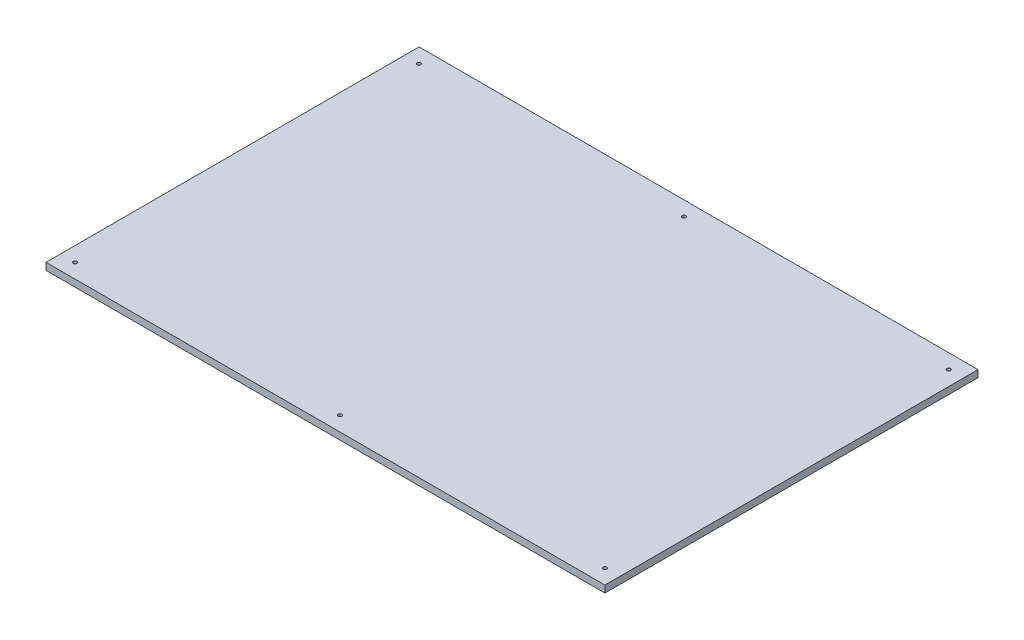
from build123d import *

# Parameters (mm, degrees)
SKETCH1_W                       = 2030
SKETCH1_H                       = 1355
BOSS_EXTRUDE1_DEPTH             = 25.4
CBORE_FOR_M12_SHCS1_D           = 13.5
CBORE_FOR_M12_SHCS1_CBORE_D     = 20
CBORE_FOR_M12_SHCS1_CBORE_DEPTH = 12


with BuildPart() as part:
    # Sketch1 → Boss-Extrude1 (new body)
    with BuildSketch(Plane(origin=(0, 0, 0), x_dir=(1, 0, 0), z_dir=(0, 1, 0))):
        with Locations((0, 125)):
            Rectangle(SKETCH1_W, SKETCH1_H)
    extrude(amount=BOSS_EXTRUDE1_DEPTH)

    # CBORE for M12 SHCS1 (through all)
    with Locations(Plane(origin=(0, 0, 0), x_dir=(-1, 0, 0), z_dir=(0, -1, 0))):
        with Locations((-962, -499.5), (-962, 749.5), (0, 749.5), (962, 749.5), (962, -499.5), (0, -499.5)):
            CounterBoreHole(CBORE_FOR_M12_SHCS1_D / 2, CBORE_FOR_M12_SHCS1_CBORE_D / 2, CBORE_FOR_M12_SHCS1_CBORE_DEPTH)


solid = part.part
